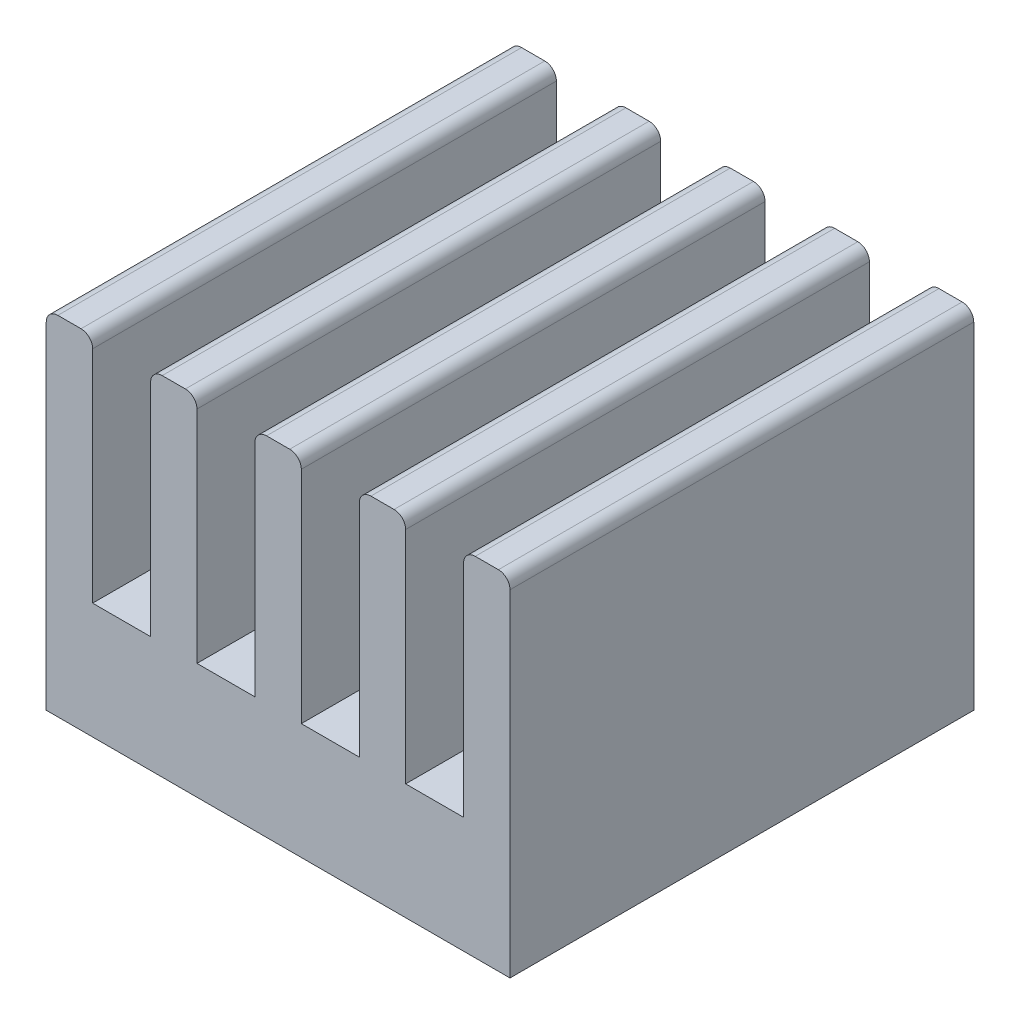
from build123d import *

# Parameters (mm, degrees)
BOSS_EXTRUDE1_DEPTH = 8
FILLET1_R           = 0.2


with BuildPart() as part:
    # Sketch1 → Boss-Extrude1 (new body)
    with BuildSketch(Plane.XY):
        Polygon((-4, 0), (4, 0), (4, 6), (3.2, 6), (3.2, 2), (2.2, 2), (2.2, 6), (1.4, 6), (1.4, 2), (0.4, 2), (0.4, 6), (-0.4, 6), (-0.4, 2), (-1.4, 2), (-1.4, 6), (-2.2, 6), (-2.2, 2), (-3.2, 2), (-3.2, 6), (-4, 6), align=None)
    extrude(amount=BOSS_EXTRUDE1_DEPTH)

    # Fillet1
    fillet1_edges = [part.edges().sort_by_distance(p)[0] for p in [
        (-4, 6, 4),
        (-3.2, 6, 4),
        (-2.2, 6, 4),
        (-1.4, 6, 4),
        (-0.4, 6, 4),
        (0.4, 6, 4),
        (1.4, 6, 4),
        (2.2, 6, 4),
        (3.2, 6, 4),
        (4, 6, 4),
    ]]
    fillet(fillet1_edges, radius=FILLET1_R)


solid = part.part
